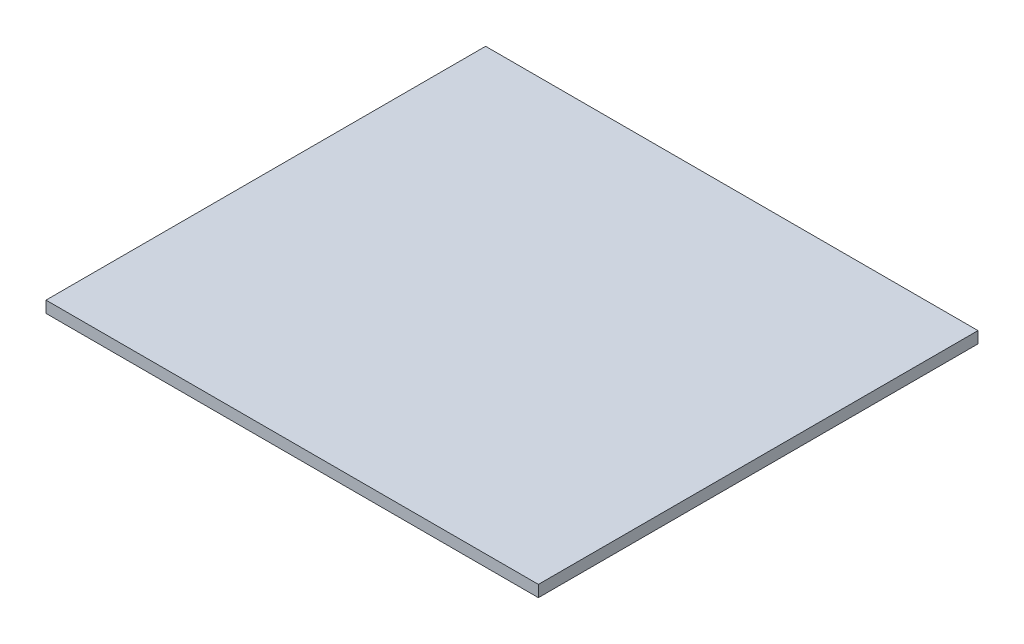
from build123d import *

# Parameters (mm, degrees)
SKETCH1_W      = 59.7
SKETCH1_H      = 53.3
EXTRUDE1_DEPTH = 1.4


with BuildPart() as part:
    # Sketch1 → Extrude1 (new body)
    with BuildSketch(Plane(origin=(0, 0, 0), x_dir=(1, 0, 0), z_dir=(0, 1, 0))):
        Rectangle(SKETCH1_W, SKETCH1_H)
    extrude(amount=EXTRUDE1_DEPTH)


solid = part.part
